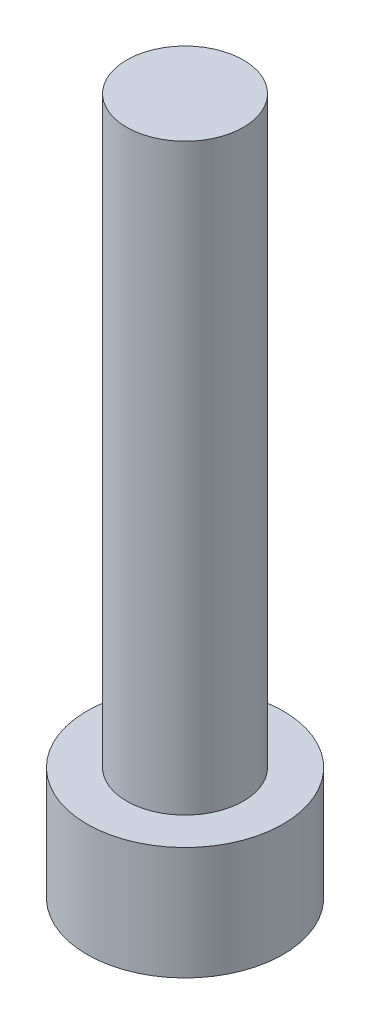
from build123d import *

# Parameters (mm, degrees)
SKETCH_1_R          = 4.2
EXTRUDE_1_DEPTH     = 4.84
SKETCH_2_R          = 2.5
EXTRUDE_2_DEPTH     = 25
CUT_EXTRUDE_1_DEPTH = 3.4


with BuildPart() as part:
    # 草图1 → 凸台-拉伸1 (new body)
    with BuildSketch(Plane(origin=(0, 0, 0), x_dir=(1, 0, 0), z_dir=(0, 1, 0))):
        Circle(SKETCH_1_R)
    extrude(amount=EXTRUDE_1_DEPTH)

    # 草图2 → 凸台-拉伸2 (add)
    with BuildSketch(Plane(origin=(0, 4.84, 0), x_dir=(1, 0, 0), z_dir=(0, 1, 0))):
        Circle(SKETCH_2_R)
    extrude(amount=EXTRUDE_2_DEPTH)

    # 草图3 → 切除-拉伸1 (cut)
    with BuildSketch(Plane.XZ):
        Polygon((2.3, 0), (1.15, 1.991858429), (-1.15, 1.991858429), (-2.3, 0), (-1.15, -1.991858429), (1.15, -1.991858429), align=None)
    extrude(amount=-CUT_EXTRUDE_1_DEPTH, mode=Mode.SUBTRACT)


solid = part.part
